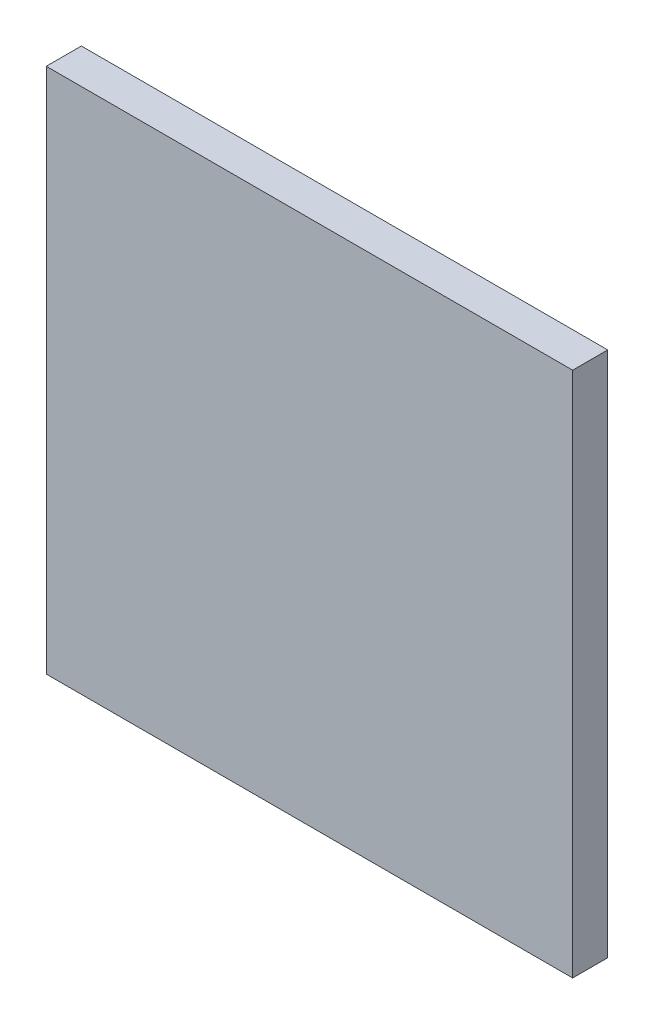
from build123d import *

# Parameters (mm, degrees)
SKETCH1_W               = 15
SKETCH1_H               = 15
COMPONENT_OUTLINE_DEPTH = 1


with BuildPart() as part:
    # Sketch1 → Component_Outline (new body)
    with BuildSketch(Plane.XY):
        Rectangle(SKETCH1_W, SKETCH1_H)
    extrude(amount=COMPONENT_OUTLINE_DEPTH)


solid = part.part
